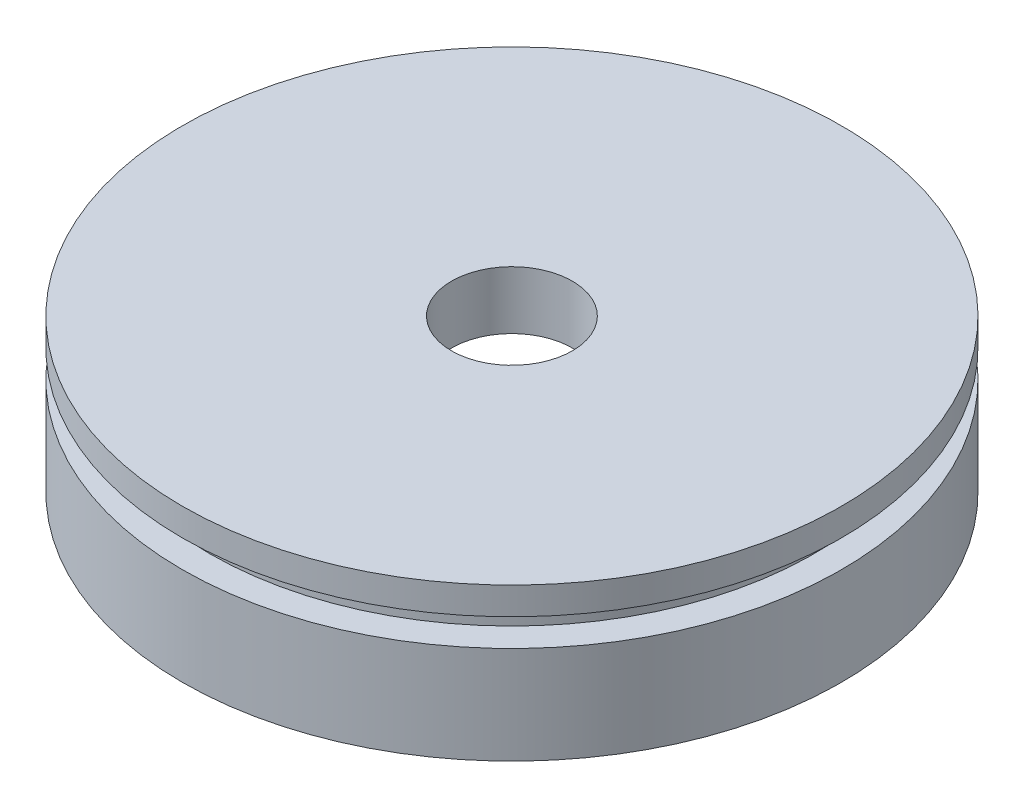
from build123d import *


with BuildPart() as part:
    # Sketch1 → Revolve1 (revolve)
    with BuildSketch(Plane.XY):
        with BuildLine():
            Line((-69.85, 1876.044), (-69.85, 1869.694))
            Line((-69.85, 1869.694), (-76.2, 1869.694))
            Line((-76.2, 1869.694), (-76.2, 1847.131150075))
            ThreePointArc((-76.2, 1847.131150075), (-46.391426486, 1861.781499782), (-13.97, 1868.995022229))
            Line((-13.97, 1868.995022229), (-13.97, 1882.394))
            Line((-13.97, 1882.394), (-76.2, 1882.394))
            Line((-76.2, 1882.394), (-76.2, 1876.044))
            Line((-76.2, 1876.044), (-69.85, 1876.044))
        make_face()
    revolve(axis=Axis((0, 50.358015581, 0), (0, -1, 0)))


solid = part.part
